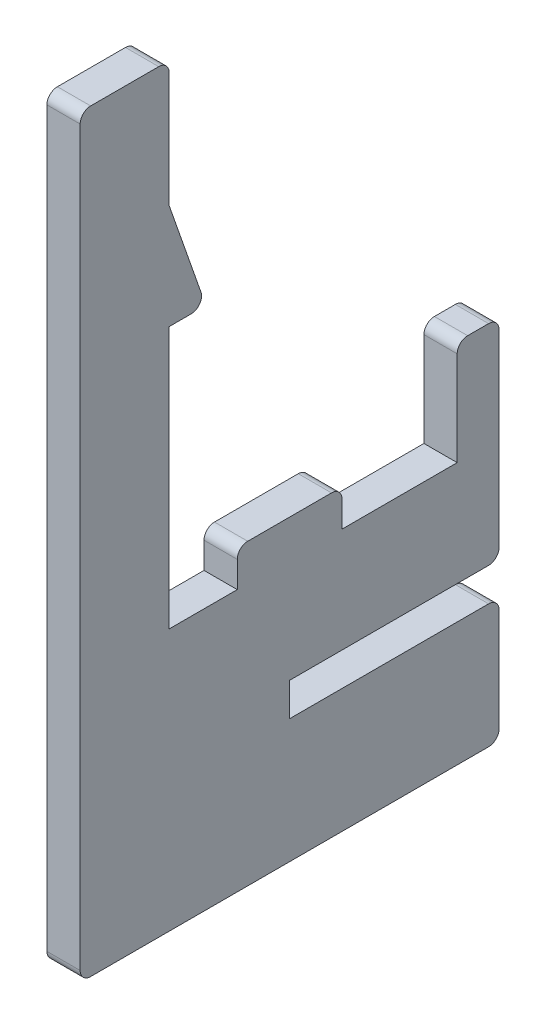
from build123d import *

# Parameters (mm, degrees)
BOSS_EXTRUDE1_DEPTH = 3.175
FILLET1_R           = 1


with BuildPart() as part:
    # Sketch1 → Boss-Extrude1 (new body)
    with BuildSketch(Plane(origin=(0, 0, 0), x_dir=(0, 0, -1), z_dir=(1, 0, 0))):
        Polygon((0, 47), (-8.5, 47), (-8.5, -10), (31.5, -10), (31.5, 10), (27.5, 10), (27.5, 0), (16.5, 0), (16.5, 3.5), (6.5, 3.5), (6.5, 0), (0, 0), (0, 25), (3.5, 25), (0, 35), align=None)
        Polygon((11.5, -10), (-8.5, -10), (-8.5, -25), (31.5, -25), (31.5, -13.175), (11.5, -13.175), align=None)
    extrude(amount=BOSS_EXTRUDE1_DEPTH)

    # Fillet1
    fillet1_edges = [part.edges().sort_by_distance(p)[0] for p in [
        (1.5875, 47, 0),
        (1.5875, 25, -3.5),
        (1.5875, 3.5, -6.5),
        (1.5875, 3.5, -16.5),
        (1.5875, 10, -27.5),
        (1.5875, 10, -31.5),
        (1.5875, -10, -31.5),
        (1.5875, -13.175, -31.5),
        (1.5875, -25, -31.5),
        (1.5875, -25, 8.5),
        (1.5875, 47, 8.5),
    ]]
    fillet(fillet1_edges, radius=FILLET1_R)


solid = part.part
